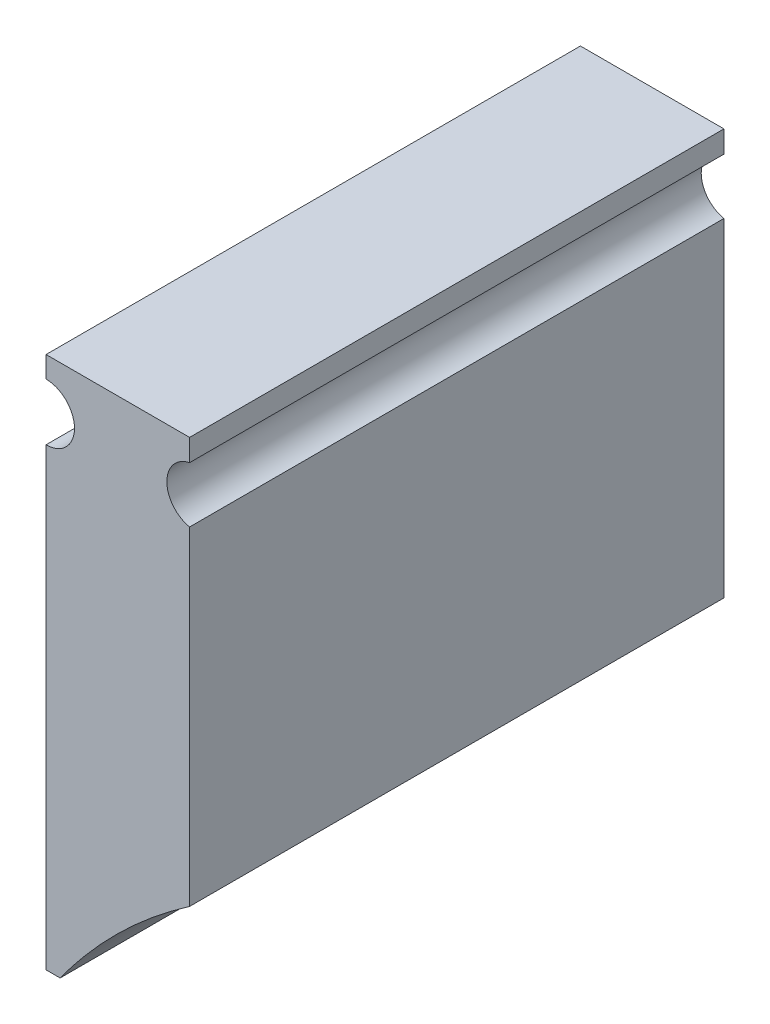
from build123d import *

# Parameters (mm, degrees)
ESQUISSE1_W             = 5.1308
ESQUISSE1_H             = 19.1008
BOSS_EXTRU_1_DEPTH      = 19.05
ENL_V_MAT_EXTRU_1_DEPTH = 20.304
ENL_V_MAT_EXTRU_2_DEPTH = 20.3040001


with BuildPart() as part:
    # Esquisse1 → Boss.-Extru.1 (new body)
    with BuildSketch(Plane(origin=(0, 0, 0), x_dir=(1, 0, 0), z_dir=(0, 1, 0))):
        with Locations((-0.1016, 9.7536)):
            Rectangle(ESQUISSE1_W, ESQUISSE1_H)
    extrude(amount=BOSS_EXTRU_1_DEPTH)

    # Esquisse2 → Enlèv. mat.-Extru.1 (cut, through all)
    with BuildSketch(Plane.XY):
        with BuildLine():
            Line((2.4638, 4.529252061), (2.4638, 0))
            Line((2.4638, 0), (-2.164205313, 0))
            add(Edge.make_bspline(
                [(-2.164205313, 0), (-0.235595225, 2.663077002), (2.4638, 4.529252061)],
                knots=[0, 0, 0, 1, 1, 1], degree=2))
        make_face()
    extrude(amount=-ENL_V_MAT_EXTRU_1_DEPTH, mode=Mode.SUBTRACT)

    # Esquisse3 → Enlèv. mat.-Extru.2 (cut, through all)
    with BuildSketch(Plane.XY):
        with BuildLine():
            Line((-2.667, 18.288), (-2.667, 16.256))
            ThreePointArc((-2.667, 16.256), (-1.651, 17.272), (-2.667, 18.288))
        make_face()
    enl_v_mat_extru_2 = extrude(amount=-ENL_V_MAT_EXTRU_2_DEPTH, mode=Mode.SUBTRACT)

    # Symétrie1: Enlèv. mat.-Extru.2 across plane
    add(enl_v_mat_extru_2.mirror(Plane(origin=(0, 0, 0), x_dir=(0, 0, 1), z_dir=(1, 0, 0))), mode=Mode.SUBTRACT)


solid = part.part
